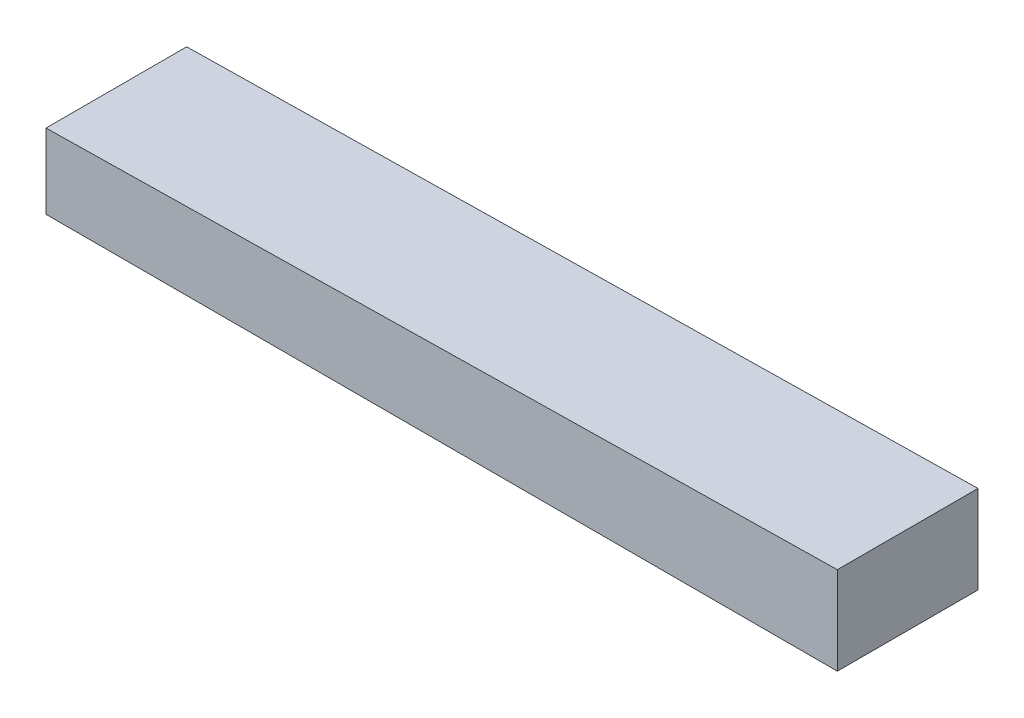
from build123d import *

# Parameters (mm, degrees)
BOSS_EXTRUDE1_DEPTH = 16


with BuildPart() as part:
    # Sketch2 → Boss-Extrude1 (new body)
    with BuildSketch(Plane.XY):
        Polygon((-45, 0), (45, 0), (45, 10), (-45, 8.5), align=None)
    extrude(amount=BOSS_EXTRUDE1_DEPTH)


solid = part.part
